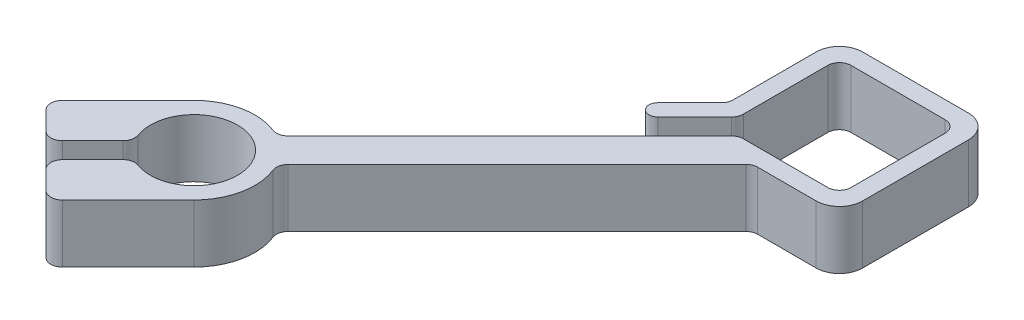
from build123d import *

# Parameters (mm, degrees)
EXTRUDE_1_DEPTH = 10
FILLET_1_R      = 2
FILLET_2_R      = 4


with BuildPart() as part:
    # Эскиз1 → Бобышка-Вытянуть1 (new body)
    with BuildSketch(Plane(origin=(0, 0, 0), x_dir=(1, 0, 0), z_dir=(0, 1, 0))):
        with BuildLine():
            Line((-13.1, 13.1), (-13.1, -6.028932188))
            Line((-13.1, -6.028932188), (-19.160660172, -12.08959236))
            ThreePointArc((-19.160660172, -12.08959236), (-19.160660172, -14.210912703), (-17.039339828, -14.210912703))
            Line((-17.039339828, -14.210912703), (-10.1, -7.271572875))
            Line((-10.1, -7.271572875), (-10.1, 10.1))
            Line((-10.1, 10.1), (10.1, 10.1))
            Line((10.1, 10.1), (10.1, -10.1))
            Line((10.1, -10.1), (-7.271572875, -10.1))
            Line((-7.271572875, -10.1), (-46.997068573, -49.825495698))
            ThreePointArc((-46.997068573, -49.825495698), (-53.506753578, -48.67194049), (-59.415494168, -51.637319575))
            Line((-59.415494168, -51.637319575), (-72.143416229, -64.365241636))
            Line((-72.143416229, -64.365241636), (-66.133008589, -70.375649276))
            Line((-66.133008589, -70.375649276), (-58.516348603, -62.75898929))
            ThreePointArc((-58.516348603, -62.75898929), (-46.687572106, -53.758639918), (-55.687921478, -65.587416415))
            Line((-55.687921478, -65.587416415), (-63.304581464, -73.204076401))
            Line((-63.304581464, -73.204076401), (-57.294173824, -79.214484041))
            Line((-57.294173824, -79.214484041), (-44.566251763, -66.48656198))
            ThreePointArc((-44.566251763, -66.48656198), (-41.600872678, -60.57782139), (-42.754427886, -54.068136385))
            Line((-42.754427886, -54.068136385), (-1.786291501, -13.1))
            Line((-1.786291501, -13.1), (13.1, -13.1))
            Line((13.1, -13.1), (13.1, 13.1))
            Line((13.1, 13.1), (-13.1, 13.1))
        make_face()
    extrude(amount=EXTRUDE_1_DEPTH)

    # Скругление1
    fillet_1_edges = [part.edges().sort_by_distance(p)[0] for p in [
        (10.1, 5, 10.1),
        (10.1, 5, -10.1),
        (-10.1, 5, -10.1),
        (-10.1, 5, 7.271572875),
        (-13.1, 5, 6.028932188),
        (-1.786291501, 5, 13.1),
        (-42.754427886, 5, 54.068136385),
        (-57.294173824, 5, 79.214484041),
        (-63.304581464, 5, 73.204076401),
        (-55.687921478, 5, 65.587416415),
        (-58.516348603, 5, 62.75898929),
        (-66.133008589, 5, 70.375649276),
        (-72.143416229, 5, 64.365241636),
        (-46.997068573, 5, 49.825495698),
        (-7.271572875, 5, 10.1),
    ]]
    fillet(fillet_1_edges, radius=FILLET_1_R)

    # Скругление2
    fillet_2_edges = [part.edges().sort_by_distance(p)[0] for p in [
        (-13.1, 5, -13.1),
        (13.1, 5, -13.1),
        (13.1, 5, 13.1),
    ]]
    fillet(fillet_2_edges, radius=FILLET_2_R)


solid = part.part
